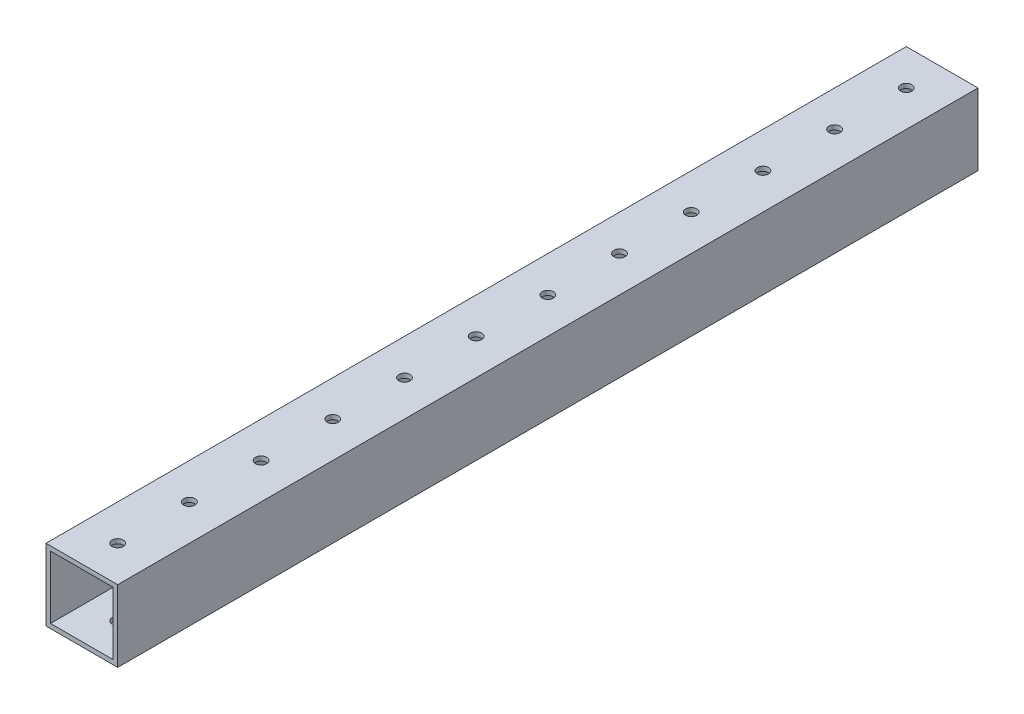
from build123d import *

# Parameters (mm, degrees)
SKETCH1_W           = 25.4
SKETCH1_H           = 25.4
SKETCH1_W_2         = 22.225
SKETCH1_H_2         = 22.225
BOSS_EXTRUDE1_DEPTH = 304.8
SKETCH2_R           = 1.984375
CUT_EXTRUDE1_DEPTH  = 26.4


with BuildPart() as part:
    # Sketch1 → Boss-Extrude1 (new body)
    with BuildSketch(Plane.XY):
        Rectangle(SKETCH1_W, SKETCH1_H)
        Rectangle(SKETCH1_W_2, SKETCH1_H_2, mode=Mode.SUBTRACT)
    extrude(amount=BOSS_EXTRUDE1_DEPTH)

    # Sketch2 → Cut-Extrude1 (cut, through all)
    with BuildSketch(Plane(origin=(0, 12.7, 0), x_dir=(1, 0, 0), z_dir=(0, 1, 0))):
        with Locations((0, -292.1)):
            Circle(SKETCH2_R)
        with Locations((0, -266.7)):
            Circle(SKETCH2_R)
        with Locations((0, -241.3)):
            Circle(SKETCH2_R)
        with Locations((0, -215.9)):
            Circle(SKETCH2_R)
        with Locations((0, -190.5)):
            Circle(SKETCH2_R)
        with Locations((0, -165.1)):
            Circle(SKETCH2_R)
        with Locations((0, -139.7)):
            Circle(SKETCH2_R)
        with Locations((0, -114.3)):
            Circle(SKETCH2_R)
        with Locations((0, -88.9)):
            Circle(SKETCH2_R)
        with Locations((0, -63.5)):
            Circle(SKETCH2_R)
        with Locations((0, -38.1)):
            Circle(SKETCH2_R)
        with Locations((0, -12.7)):
            Circle(SKETCH2_R)
    extrude(amount=-CUT_EXTRUDE1_DEPTH, mode=Mode.SUBTRACT)


solid = part.part
